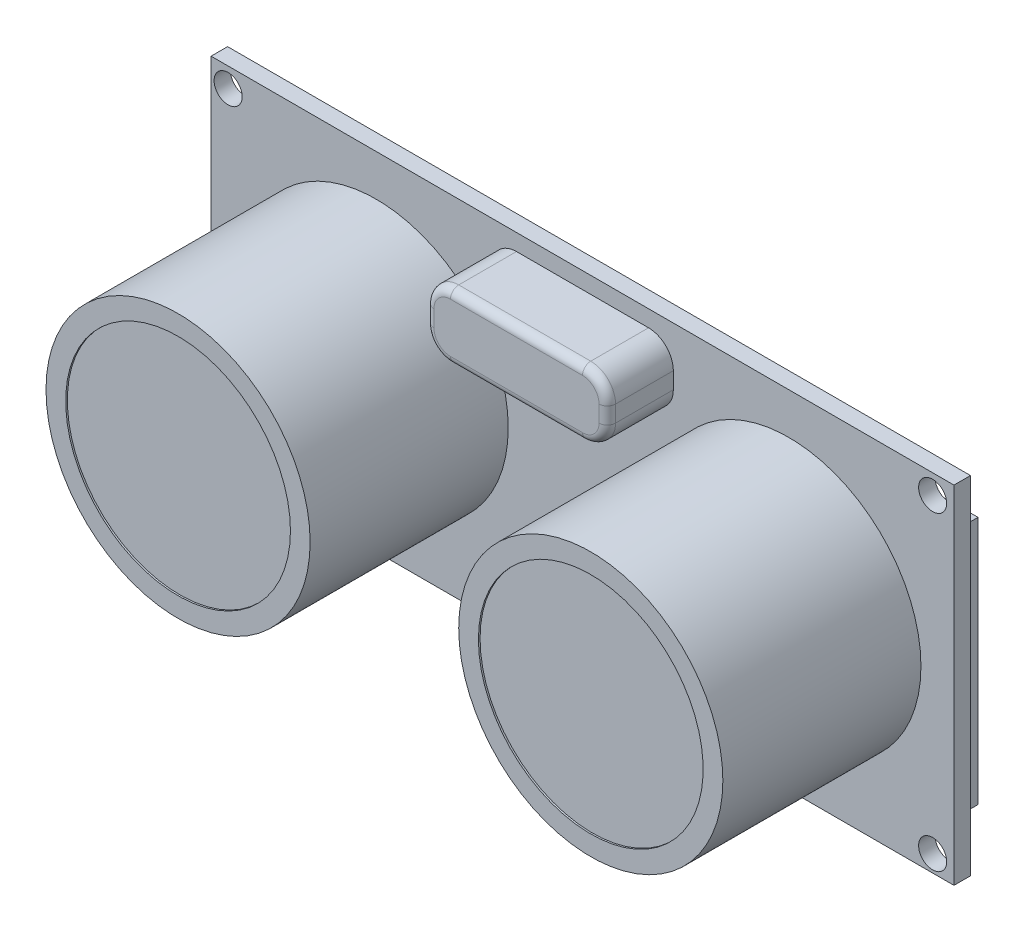
from build123d import *

# Parameters (mm, degrees)
SKIZZE2_W                       = 45
SKIZZE2_H                       = 21
AUFSATZ_LINEAR_AUSTRAGEN1_DEPTH = 1
SKIZZE3_R                       = 8
AUFSATZ_LINEAR_AUSTRAGEN2_DEPTH = 12
SKIZZE4_R                       = 6.807265198
SCHNITT_LINEAR_AUSTRAGEN1_DEPTH = 0.1
SKIZZE7_W                       = 11
SKIZZE7_H                       = 4
AUFSATZ_LINEAR_AUSTRAGEN3_DEPTH = 4
VERRUNDUNG1_R                   = 1.5
VERRUNDUNG2_R                   = 0.5
DURCHGANGSLOCH_F_R_M1_61_D      = 1.7
SKIZZE10_W                      = 43.911086724
SKIZZE10_H                      = 15.069429202
AUFSATZ_LINEAR_AUSTRAGEN4_DEPTH = 1
SKIZZE11_W                      = 11
SKIZZE11_H                      = 2.5
AUFSATZ_LINEAR_AUSTRAGEN6_DEPTH = 2
VERRUNDUNG5_R                   = 0.3


with BuildPart() as part:
    # Skizze2 → Aufsatz-Linear austragen1 (new body)
    with BuildSketch(Plane.XY):
        Rectangle(SKIZZE2_W, SKIZZE2_H)
    extrude(amount=AUFSATZ_LINEAR_AUSTRAGEN1_DEPTH)

    # Skizze3 → Aufsatz-Linear austragen2 (add)
    with BuildSketch(Plane.XY.offset(1)):
        with Locations((-12.5, 0)):
            Circle(SKIZZE3_R)
        with Locations((12.5, 0)):
            Circle(SKIZZE3_R)
    extrude(amount=AUFSATZ_LINEAR_AUSTRAGEN2_DEPTH)

    # Skizze4 → Schnitt-Linear austragen1 (cut)
    with BuildSketch(Plane.XY.offset(13)):
        with Locations((-12.5, 0)):
            Circle(SKIZZE4_R)
        with Locations((12.5, 0)):
            Circle(SKIZZE4_R)
    extrude(amount=-SCHNITT_LINEAR_AUSTRAGEN1_DEPTH, mode=Mode.SUBTRACT)

    # Skizze7 → Aufsatz-Linear austragen3 (add)
    with BuildSketch(Plane.XY.offset(1)):
        with Locations((0, 7.5)):
            Rectangle(SKIZZE7_W, SKIZZE7_H)
    extrude(amount=AUFSATZ_LINEAR_AUSTRAGEN3_DEPTH)

    # Verrundung1
    verrundung1_edges = [part.edges().sort_by_distance(p)[0] for p in [
        (-5.5, 9.5, 3),
        (-5.5, 5.5, 3),
        (5.5, 5.5, 3),
        (5.5, 9.5, 3),
    ]]
    fillet(verrundung1_edges, radius=VERRUNDUNG1_R)

    # Verrundung2
    verrundung2_edges = [part.edges().sort_by_distance(p)[0] for p in [
        (0, 5.5, 5),
        (-5.5, 7.5, 5),
        (5.5, 7.5, 5),
        (0, 9.5, 5),
        (5.060660172, 9.060660172, 5),
        (5.060660172, 5.939339828, 5),
        (-5.060660172, 9.060660172, 5),
        (-5.060660172, 5.939339828, 5),
    ]]
    fillet(verrundung2_edges, radius=VERRUNDUNG2_R)

    # Durchgangsloch für M1.61 (through all)
    with Locations(Plane.XY.offset(1)):
        with Locations((-21.468583309, 9.311267252), (-21.468583309, -9.482056215), (21.207777042, -9.482056215), (21.207777042, 9.311267252)):
            Hole(DURCHGANGSLOCH_F_R_M1_61_D / 2)

    # Skizze10 → Aufsatz-Linear austragen4 (add)
    with BuildSketch(Plane(origin=(0, 0, 0), x_dir=(-1, 0, 0), z_dir=(0, 0, -1))):
        Rectangle(SKIZZE10_W, SKIZZE10_H)
    extrude(amount=AUFSATZ_LINEAR_AUSTRAGEN4_DEPTH)


with BuildPart() as body_2:
    # Skizze11 → Aufsatz-Linear austragen6 (new body)
    with BuildSketch(Plane(origin=(0, 0, 0), x_dir=(-1, 0, 0), z_dir=(0, 0, -1))):
        with Locations((0, -9.25)):
            Rectangle(SKIZZE11_W, SKIZZE11_H)
    extrude(amount=AUFSATZ_LINEAR_AUSTRAGEN6_DEPTH)

    # Verrundung5
    verrundung5_edges = [body_2.edges().sort_by_distance(p)[0] for p in [
        (5.5, -9.25, -2),
        (0, -10.5, -2),
        (-5.5, -9.25, -2),
        (0, -10.5, 0),
        (5.5, -9.25, 0),
        (0, -8, 0),
        (-5.5, -9.25, 0),
        (0, -8, -2),
        (-5.5, -10.5, -1),
        (5.5, -10.5, -1),
        (5.5, -8, -1),
        (-5.5, -8, -1),
    ]]
    fillet(verrundung5_edges, radius=VERRUNDUNG5_R)


solid = Compound([part.part, body_2.part])
